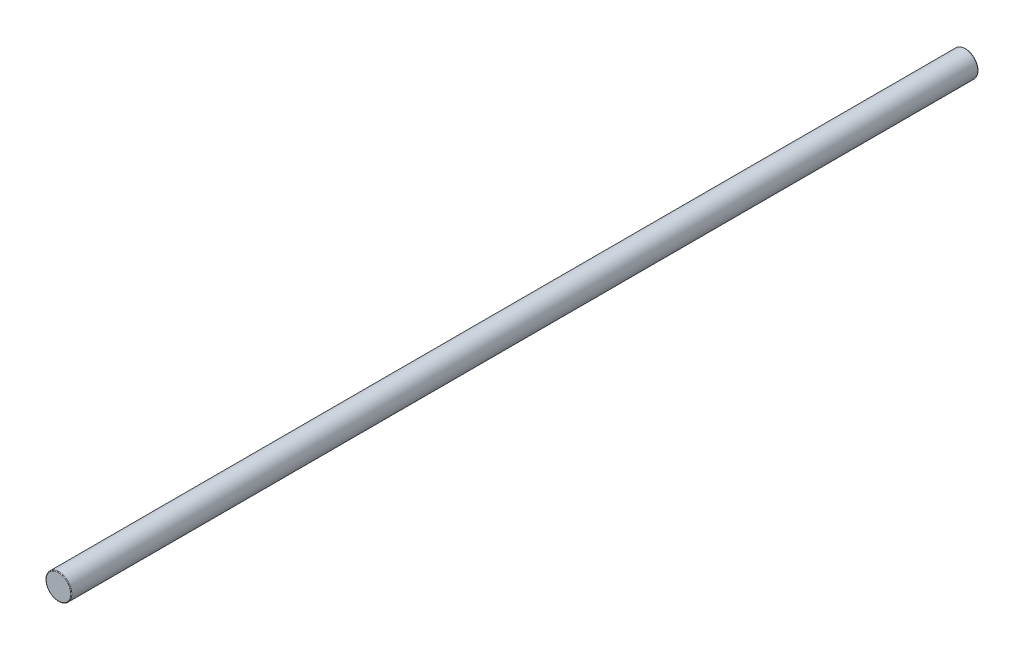
from build123d import *

# Parameters (mm, degrees)
SKETCH1_R           = 4
BOSS_EXTRUDE1_DEPTH = 283
FILLET1_R           = 0.2


with BuildPart() as part:
    # Sketch1 → Boss-Extrude1 (new body)
    with BuildSketch(Plane.XY):
        Circle(SKETCH1_R)
    extrude(amount=-BOSS_EXTRUDE1_DEPTH)

    # Fillet1
    fillet1_edges = [part.edges().sort_by_distance(p)[0] for p in [
        (-4, 0, 0),
        (-4, 0, -283),
    ]]
    fillet(fillet1_edges, radius=FILLET1_R)


solid = part.part
